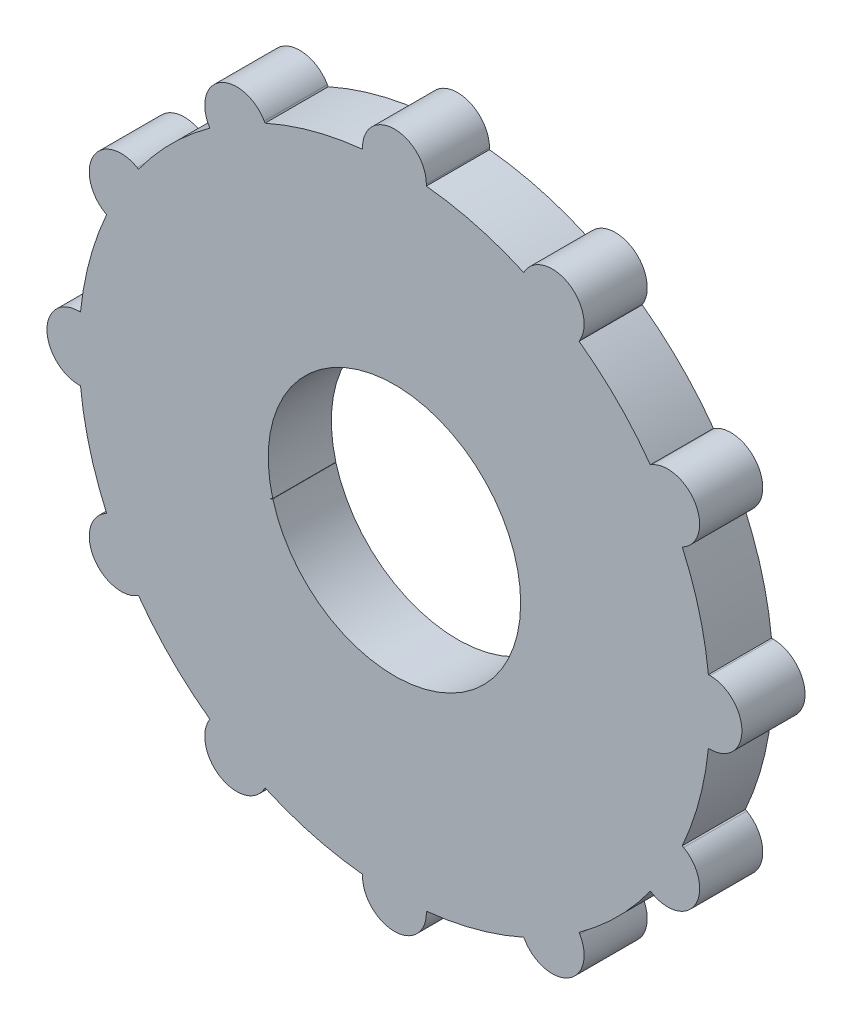
from build123d import *

# Parameters (mm, degrees)
BOSS_EXTRUDE1_DEPTH = 10


with BuildPart() as part:
    # Sketch1 → Boss-Extrude1 (new body)
    with BuildSketch(Plane.XY):
        with BuildLine():
            Line((-5.055544828, 50), (-5.055544828, 49.743758066))
            ThreePointArc((-5.055544828, 49.743758066), (-12.940952255, 48.296291315), (-20.493648782, 45.607130579))
            Line((-20.493648782, 45.607130579), (-20.621769749, 45.829042603))
            ThreePointArc((-20.621769749, 45.829042603), (-27.527772414, 47.67950044), (-29.378230251, 40.773497775))
            Line((-29.378230251, 40.773497775), (-29.250109284, 40.551585751))
            ThreePointArc((-29.250109284, 40.551585751), (-35.355339059, 35.355339059), (-40.551585751, 29.250109284))
            Line((-40.551585751, 29.250109284), (-40.773497775, 29.378230251))
            ThreePointArc((-40.773497775, 29.378230251), (-47.67950044, 27.527772414), (-45.829042603, 20.621769749))
            Line((-45.829042603, 20.621769749), (-45.607130579, 20.493648782))
            ThreePointArc((-45.607130579, 20.493648782), (-48.296291315, 12.940952255), (-49.743758066, 5.055544828))
            Line((-49.743758066, 5.055544828), (-50, 5.055544828))
            ThreePointArc((-50, 5.055544828), (-55.055544828, 0), (-50, -5.055544828))
            Line((-50, -5.055544828), (-49.743758066, -5.055544828))
            ThreePointArc((-49.743758066, -5.055544828), (-48.296291315, -12.940952255), (-45.607130579, -20.493648782))
            Line((-45.607130579, -20.493648782), (-45.829042603, -20.621769749))
            ThreePointArc((-45.829042603, -20.621769749), (-47.67950044, -27.527772414), (-40.773497775, -29.378230251))
            Line((-40.773497775, -29.378230251), (-40.551585751, -29.250109284))
            ThreePointArc((-40.551585751, -29.250109284), (-35.355339059, -35.355339059), (-29.250109284, -40.551585751))
            Line((-29.250109284, -40.551585751), (-29.378230251, -40.773497775))
            ThreePointArc((-29.378230251, -40.773497775), (-27.527772414, -47.67950044), (-20.621769749, -45.829042603))
            Line((-20.621769749, -45.829042603), (-20.493648782, -45.607130579))
            ThreePointArc((-20.493648782, -45.607130579), (-12.940952255, -48.296291315), (-5.055544828, -49.743758066))
            Line((-5.055544828, -49.743758066), (-5.055544828, -50))
            ThreePointArc((-5.055544828, -50), (0, -55.055544828), (5.055544828, -50))
            Line((5.055544828, -50), (5.055544828, -49.743758066))
            ThreePointArc((5.055544828, -49.743758066), (12.940952255, -48.296291315), (20.493648782, -45.607130579))
            Line((20.493648782, -45.607130579), (20.621769749, -45.829042603))
            ThreePointArc((20.621769749, -45.829042603), (27.527772414, -47.67950044), (29.378230251, -40.773497775))
            Line((29.378230251, -40.773497775), (29.250109284, -40.551585751))
            ThreePointArc((29.250109284, -40.551585751), (35.355339059, -35.355339059), (40.551585751, -29.250109284))
            Line((40.551585751, -29.250109284), (40.773497775, -29.378230251))
            ThreePointArc((40.773497775, -29.378230251), (47.67950044, -27.527772414), (45.829042603, -20.621769749))
            Line((45.829042603, -20.621769749), (45.607130579, -20.493648782))
            ThreePointArc((45.607130579, -20.493648782), (48.296291315, -12.940952255), (49.743758066, -5.055544828))
            Line((49.743758066, -5.055544828), (50, -5.055544828))
            ThreePointArc((50, -5.055544828), (55.055544828, 0), (50, 5.055544828))
            Line((50, 5.055544828), (49.743758066, 5.055544828))
            ThreePointArc((49.743758066, 5.055544828), (48.296291315, 12.940952255), (45.607130579, 20.493648782))
            Line((45.607130579, 20.493648782), (45.829042603, 20.621769749))
            ThreePointArc((45.829042603, 20.621769749), (47.67950044, 27.527772414), (40.773497775, 29.378230251))
            Line((40.773497775, 29.378230251), (40.551585751, 29.250109284))
            ThreePointArc((40.551585751, 29.250109284), (35.355339059, 35.355339059), (29.250109284, 40.551585751))
            Line((29.250109284, 40.551585751), (29.378230251, 40.773497775))
            ThreePointArc((29.378230251, 40.773497775), (27.527772414, 47.67950044), (20.621769749, 45.829042603))
            Line((20.621769749, 45.829042603), (20.493648782, 45.607130579))
            ThreePointArc((20.493648782, 45.607130579), (12.940952255, 48.296291315), (5.055544828, 49.743758066))
            Line((5.055544828, 49.743758066), (5.055544828, 50))
            ThreePointArc((5.055544828, 50), (0, 55.055544828), (-5.055544828, 50))
        make_face()
        with BuildLine():
            ThreePointArc((-19.274651306, -5.337397964), (-19.565972123, -5.470493987), (-19.84828049, -5.621769749))
            Line((-19.84828049, -5.621769749), (-19.285788402, -5.297014791))
            ThreePointArc((-19.285788402, -5.297014791), (-19.323926995, -5.156146381), (-19.361036662, -5.015003426))
            ThreePointArc((-19.361036662, -5.015003426), (-20, 0), (-19.361036662, 5.015003426))
            ThreePointArc((-19.361036662, 5.015003426), (-19.318516526, 5.176380902), (-19.274651306, 5.337397964))
            ThreePointArc((-19.274651306, 5.337397964), (-17.320508076, 10), (-14.25964788, 14.023638698))
            ThreePointArc((-14.25964788, 14.023638698), (-14.142135624, 14.142135624), (-14.023638698, 14.25964788))
            ThreePointArc((-14.023638698, 14.25964788), (-10, 17.320508076), (-5.337397964, 19.274651306))
            ThreePointArc((-5.337397964, 19.274651306), (-5.176380902, 19.318516526), (-5.015003426, 19.361036662))
            ThreePointArc((-5.015003426, 19.361036662), (0, 20), (5.015003426, 19.361036662))
            ThreePointArc((5.015003426, 19.361036662), (5.176380902, 19.318516526), (5.337397964, 19.274651306))
            ThreePointArc((5.337397964, 19.274651306), (10, 17.320508076), (14.023638698, 14.25964788))
            ThreePointArc((14.023638698, 14.25964788), (14.142135624, 14.142135624), (14.25964788, 14.023638698))
            ThreePointArc((14.25964788, 14.023638698), (17.320508076, 10), (19.274651306, 5.337397964))
            ThreePointArc((19.274651306, 5.337397964), (19.318516526, 5.176380902), (19.361036662, 5.015003426))
            ThreePointArc((19.361036662, 5.015003426), (19.839616091, 2.527772414), (20, 0))
            ThreePointArc((20, 0), (19.839616091, -2.527772414), (19.361036662, -5.015003426))
            ThreePointArc((19.361036662, -5.015003426), (19.318516526, -5.176380902), (19.274651306, -5.337397964))
            ThreePointArc((19.274651306, -5.337397964), (17.320508076, -10), (14.25964788, -14.023638698))
            ThreePointArc((14.25964788, -14.023638698), (14.142135624, -14.142135624), (14.023638698, -14.25964788))
            ThreePointArc((14.023638698, -14.25964788), (10, -17.320508076), (5.337397964, -19.274651306))
            ThreePointArc((5.337397964, -19.274651306), (5.176380902, -19.318516526), (5.015003426, -19.361036662))
            ThreePointArc((5.015003426, -19.361036662), (0, -20), (-5.015003426, -19.361036662))
            ThreePointArc((-5.015003426, -19.361036662), (-5.176380902, -19.318516526), (-5.337397964, -19.274651306))
            ThreePointArc((-5.337397964, -19.274651306), (-10, -17.320508076), (-14.023638698, -14.25964788))
            ThreePointArc((-14.023638698, -14.25964788), (-14.142135624, -14.142135624), (-14.25964788, -14.023638698))
            ThreePointArc((-14.25964788, -14.023638698), (-17.320508076, -10), (-19.274651306, -5.337397964))
        make_face(mode=Mode.SUBTRACT)
    extrude(amount=BOSS_EXTRUDE1_DEPTH)


solid = part.part
